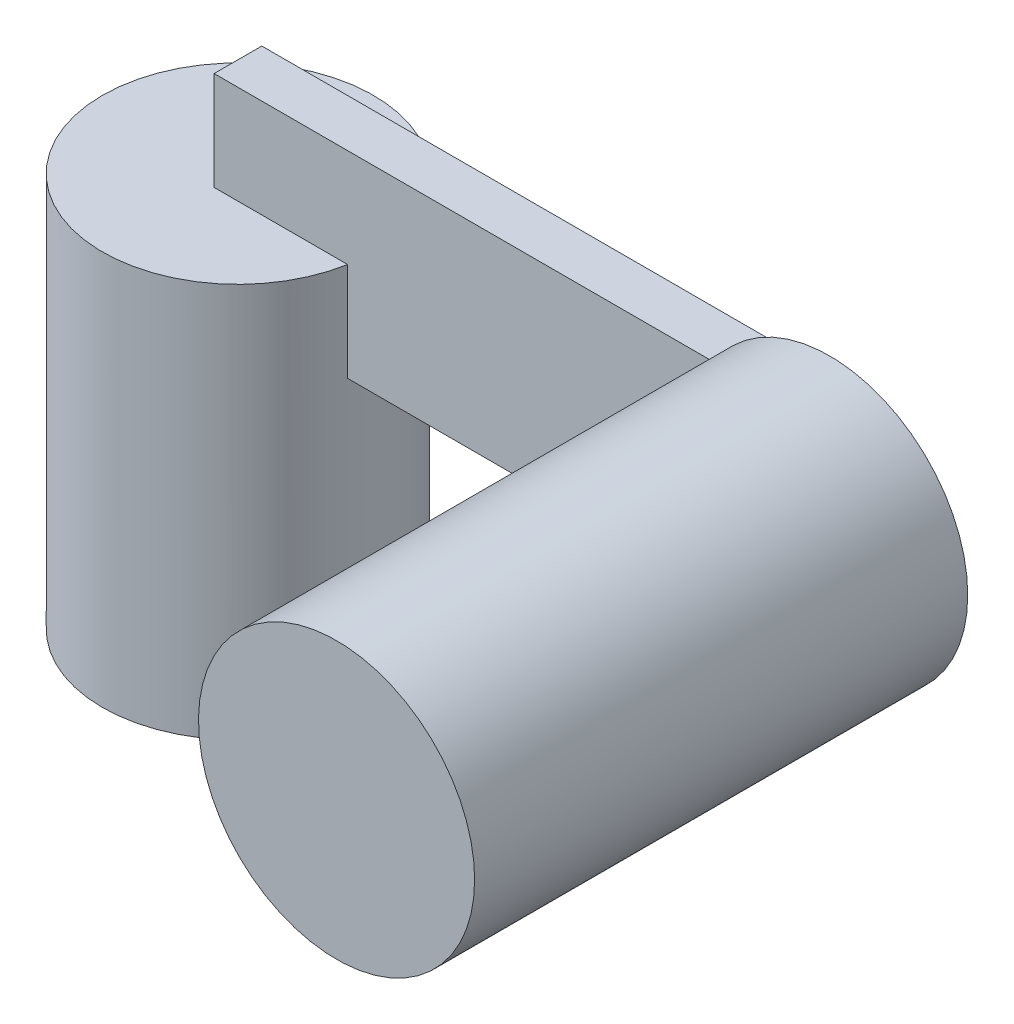
from build123d import *

# Parameters (mm, degrees)
SKETCH1_R           = 6.875
BOSS_EXTRUDE1_DEPTH = 20
SKETCH2_W           = 2.41756572
SKETCH2_H           = 10
BOSS_EXTRUDE2_DEPTH = 30
SKETCH3_R           = 7
BOSS_EXTRUDE3_DEPTH = 25


with BuildPart() as part:
    # Sketch1 → Boss-Extrude1 (new body)
    with BuildSketch(Plane(origin=(0, 0, 0), x_dir=(1, 0, 0), z_dir=(0, 1, 0))):
        Circle(SKETCH1_R)
    extrude(amount=BOSS_EXTRUDE1_DEPTH)

    # Sketch2 → Boss-Extrude2 (add)
    with BuildSketch(Plane(origin=(0, 0, 0), x_dir=(0, 0, -1), z_dir=(1, 0, 0))):
        with Locations((0, 20)):
            Rectangle(SKETCH2_W, SKETCH2_H)
    extrude(amount=BOSS_EXTRUDE2_DEPTH)

    # Sketch3 → Boss-Extrude3 (add)
    with BuildSketch(Plane.XY):
        with Locations((30, 20)):
            Circle(SKETCH3_R)
    extrude(amount=BOSS_EXTRUDE3_DEPTH)


solid = part.part
